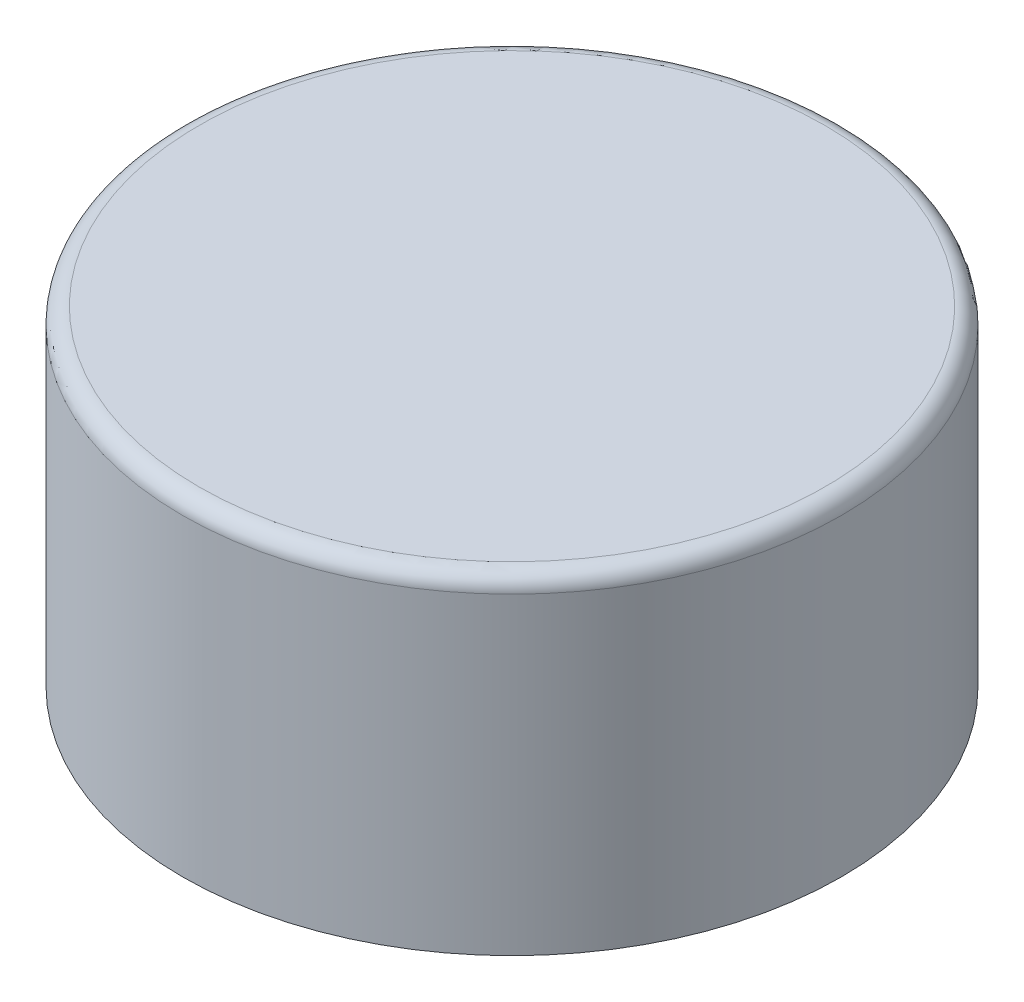
from build123d import *

# Parameters (mm, degrees)
SKETCH_1_R        = 40
EXTRUDE_1_DEPTH   = 20
FILLET_1_R        = 2
SWEEP_3_PROFILE_R = 0.75
SKETCH_2_W        = 0.5
SKETCH_2_H        = 1


with BuildPart() as part:
    # 草图1 → 凸台-拉伸1 (new body, symmetric)
    with BuildSketch(Plane(origin=(0, 0, 0), x_dir=(1, 0, 0), z_dir=(0, 1, 0))):
        Circle(SKETCH_1_R)
    extrude(amount=EXTRUDE_1_DEPTH, both=True)

    # 圆角1
    fillet_1_edges = [part.edges().sort_by_distance(p)[0] for p in [
        (-40, 20, 0),
    ]]
    fillet(fillet_1_edges, radius=FILLET_1_R)

    # 切除-扫描3: sweep along a path in 草图3
    with BuildLine(Plane.XZ.offset(20)) as sweep_3_path:
        CenterArc((0, 0), 9, 0, 360)
    # 切除-扫描3 profile (on start of the path) → 切除-扫描3 (sweep, cut)
    with BuildSketch(Plane(origin=(9, -20, 0), x_dir=(1, 0, 0), z_dir=(0, 0, 1))):
        Circle(SWEEP_3_PROFILE_R)
    sweep(path=sweep_3_path.line, mode=Mode.SUBTRACT)

    # 草图2 → 切除-旋转1 (revolve, cut)
    with BuildSketch(Plane.XY):
        with Locations((0.25, 0.5)):
            Rectangle(SKETCH_2_W, SKETCH_2_H)
    revolve(axis=Axis((0, 0, 0), (0, 1, 0)), mode=Mode.SUBTRACT)


solid = part.part
